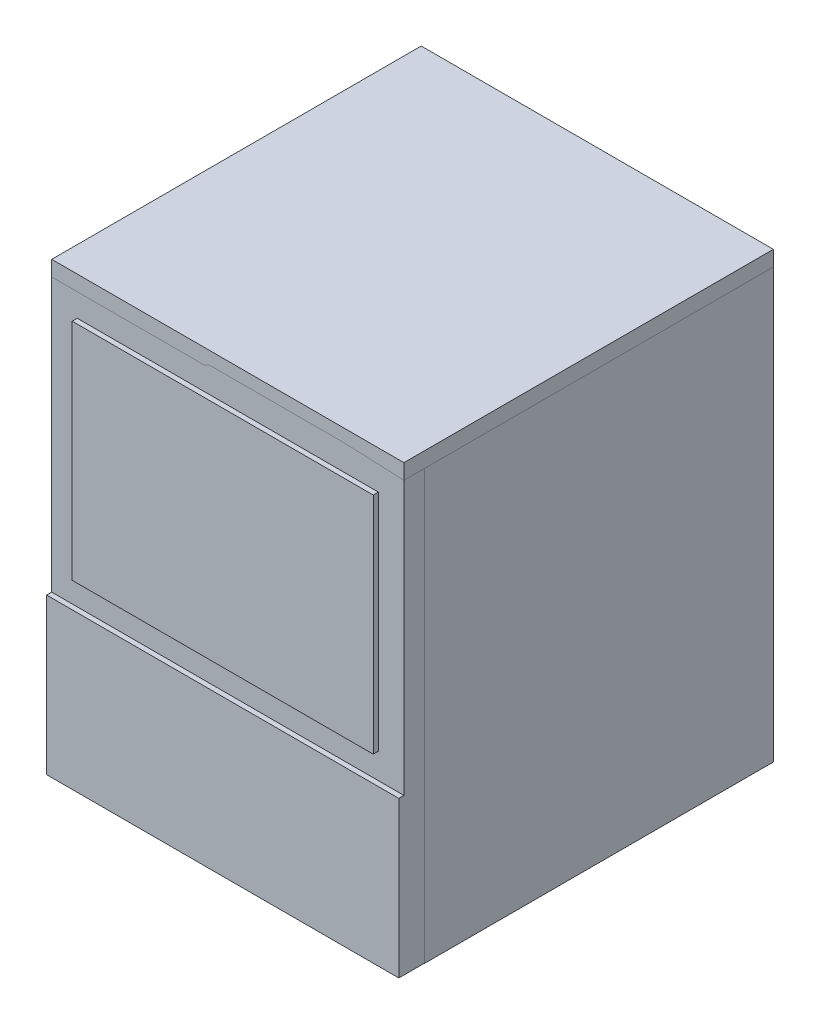
from build123d import *

# Parameters (mm, degrees)
SKETCH2_W                = 690
SKETCH2_H                = 683.9
BOSS_EXTRUDE1_DEPTH      = 0.5
SKETCH4_W                = 690
SKETCH4_H                = 683.9
SKETCH4_W_2              = 670
SKETCH4_H_2              = 663.9
BOSS_EXTRUDE3_DEPTH      = 845
SKETCH12_W               = 690
SKETCH12_H               = 723.9
BOSS_EXTRUDE4_DEPTH      = 10
SKETCH13_W               = 690
SKETCH13_H               = 723.9
SKETCH13_W_2             = 670
SKETCH13_H_2             = 703.9
BOSS_EXTRUDE5_DEPTH      = 30
SKETCH11_W               = 530
SKETCH11_H               = 349.7
CUT_EXTRUDE1_DEPTH       = 10
SKETCH15_W               = 690
SKETCH15_H               = 844.5
BOSS_EXTRUDE6_DEPTH      = 10
SKETCH14_W               = 690
SKETCH14_H               = 304.8
SKETCH14_W_2             = 590
SKETCH14_H_2             = 439.7
BOSS_EXTRUDE7_DEPTH      = 10
BOSS_EXTRUDE7_DEPTH_BACK = 30
SKETCH17_W               = 690
SKETCH17_H               = 844.5
SKETCH17_W_2             = 670
SKETCH17_H_2             = 824.5
BOSS_EXTRUDE8_DEPTH      = 40


with BuildPart() as part:
    # Sketch2 → Boss-Extrude1 (new body)
    with BuildSketch(Plane(origin=(0, -89, 0), x_dir=(1, 0, 0), z_dir=(0, 1, 0))):
        Rectangle(SKETCH2_W, SKETCH2_H)
    extrude(amount=BOSS_EXTRUDE1_DEPTH)


with BuildPart() as body_2:
    # Sketch4 → Boss-Extrude3 (new body)
    with BuildSketch(Plane(origin=(0, -89, 0), x_dir=(1, 0, 0), z_dir=(0, 1, 0))):
        Rectangle(SKETCH4_W, SKETCH4_H)
        Rectangle(SKETCH4_W_2, SKETCH4_H_2, mode=Mode.SUBTRACT)
    extrude(amount=BOSS_EXTRUDE3_DEPTH)

    # Sketch11 → Cut-Extrude1 (cut)
    with BuildSketch(Plane.XY.offset(341.95)):
        with Locations((0, 481.15)):
            Rectangle(SKETCH11_W, SKETCH11_H)
    extrude(amount=-CUT_EXTRUDE1_DEPTH, mode=Mode.SUBTRACT)


with BuildPart() as body_3:
    # Sketch12 → Boss-Extrude4 (new body)
    with BuildSketch(Plane(origin=(0, 781, 0), x_dir=(1, 0, 0), z_dir=(0, 1, 0))):
        with Locations((0, -20)):
            Rectangle(SKETCH12_W, SKETCH12_H)
    extrude(amount=-BOSS_EXTRUDE4_DEPTH)

    # Sketch13 → Boss-Extrude5 (add)
    with BuildSketch(Plane(origin=(0, 781, 0), x_dir=(1, 0, 0), z_dir=(0, 1, 0))):
        with Locations((0, -20)):
            Rectangle(SKETCH13_W, SKETCH13_H)
        with Locations((0, -20)):
            Rectangle(SKETCH13_W_2, SKETCH13_H_2, mode=Mode.SUBTRACT)
    extrude(amount=-BOSS_EXTRUDE5_DEPTH)


with BuildPart() as body_4:
    # Sketch15 → Boss-Extrude6 (new body)
    with BuildSketch(Plane.XY.offset(381.95)):
        with Locations((0, 333.75)):
            Rectangle(SKETCH15_W, SKETCH15_H)
    extrude(amount=-BOSS_EXTRUDE6_DEPTH)

    # Sketch14 → Boss-Extrude7 (add, two sides)
    with BuildSketch(Plane.XY.offset(381.95)) as boss_extrude7_sk:
        with Locations((0, 63.9)):
            Rectangle(SKETCH14_W, SKETCH14_H)
        with Locations((0, 486.15)):
            Rectangle(SKETCH14_W_2, SKETCH14_H_2)
    extrude(amount=BOSS_EXTRUDE7_DEPTH)
    extrude(boss_extrude7_sk.sketch, amount=-BOSS_EXTRUDE7_DEPTH_BACK)

    # Sketch17 → Boss-Extrude8 (add)
    with BuildSketch(Plane.XY.offset(381.95)):
        with Locations((0, 333.75)):
            Rectangle(SKETCH17_W, SKETCH17_H)
        with Locations((0, 333.75)):
            Rectangle(SKETCH17_W_2, SKETCH17_H_2, mode=Mode.SUBTRACT)
    extrude(amount=-BOSS_EXTRUDE8_DEPTH)


solid = Compound([part.part, body_2.part, body_3.part, body_4.part])
